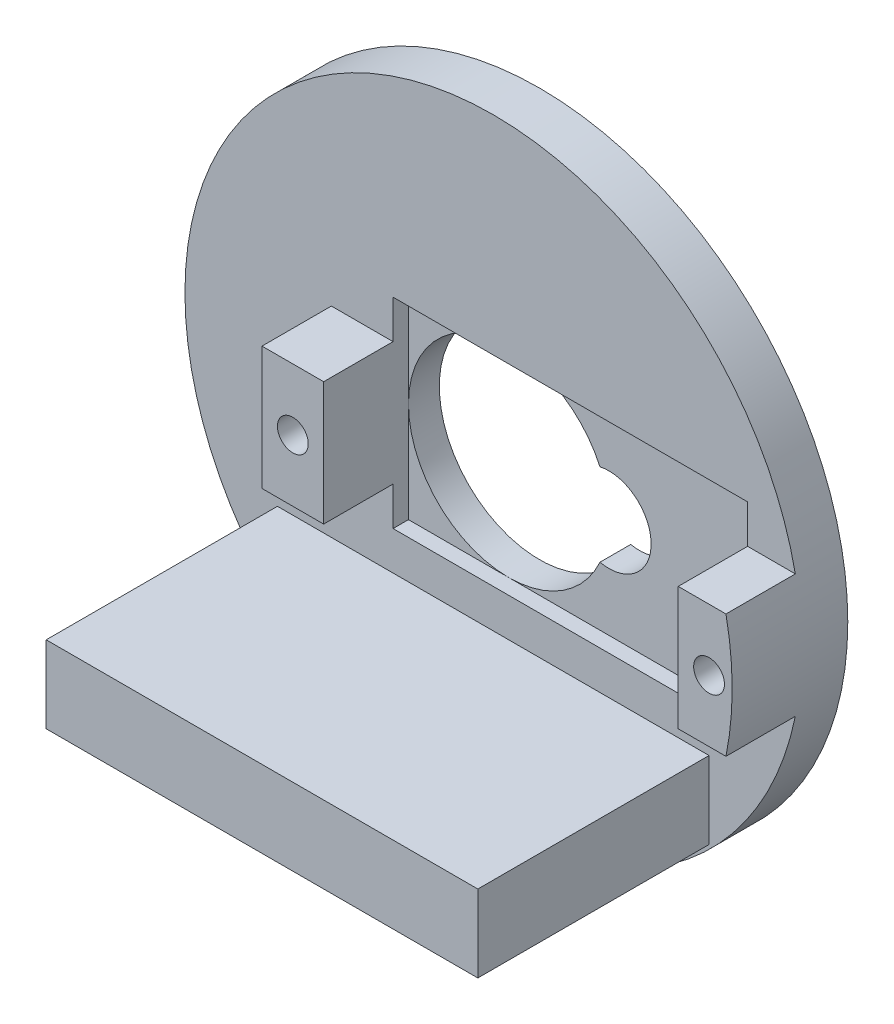
from build123d import *

# Parameters (mm, degrees)
ESBO_O1_R                = 20
RESSALTO_EXTRUS_O1_DEPTH = 3
ESBO_O2_W                = 4
ESBO_O2_H                = 8
ESBO_O2_R                = 1
RESSALTO_EXTRUS_O3_DEPTH = 4.5
ESBO_O3_W                = 23
ESBO_O3_H                = 13
CORTE_EXTRUS_O1_DEPTH    = 1
ESBO_O4_W                = 28
ESBO_O4_H                = 5
RESSALTO_EXTRUS_O4_DEPTH = 15


with BuildPart() as part:
    # Esboço1 → Ressalto-extrusão1 (new body)
    with BuildSketch(Plane.XY):
        Circle(ESBO_O1_R)
        with BuildLine():
            ThreePointArc((5.921389022, 2.680886429), (-6.5, 0), (5.921389022, -2.680886429))
            ThreePointArc((5.921389022, -2.680886429), (9.242616034, 0), (5.921389022, 2.680886429))
        make_face(mode=Mode.SUBTRACT)
    extrude(amount=RESSALTO_EXTRUS_O1_DEPTH)

    # Esboço2 → Ressalto-extrusão3 (add)
    with BuildSketch(Plane.XY.offset(3)):
        with Locations((-8.5, 0)):
            Rectangle(ESBO_O2_W, ESBO_O2_H)
        with Locations((-8.5, 0)):
            Circle(ESBO_O2_R, mode=Mode.SUBTRACT)
        with BuildLine():
            Line((16.5, -4), (19.595917942, -4))
            ThreePointArc((19.595917942, -4), (20, 0), (19.595917942, 4))
            Line((19.595917942, 4), (16.5, 4))
            Line((16.5, 4), (16.5, -4))
        make_face()
        with Locations((18.5, 0)):
            Circle(ESBO_O2_R, mode=Mode.SUBTRACT)
    extrude(amount=RESSALTO_EXTRUS_O3_DEPTH)

    # Esboço3 → Corte-extrusão1 (cut)
    with BuildSketch(Plane.XY.offset(3)):
        with Locations((5, 0)):
            Rectangle(ESBO_O3_W, ESBO_O3_H)
    extrude(amount=-CORTE_EXTRUS_O1_DEPTH, mode=Mode.SUBTRACT)

    # Esboço4 → Ressalto-extrusão4 (add)
    with BuildSketch(Plane.XY.offset(3)):
        with Locations((0, -11.5)):
            Rectangle(ESBO_O4_W, ESBO_O4_H)
    extrude(amount=RESSALTO_EXTRUS_O4_DEPTH)


solid = part.part
